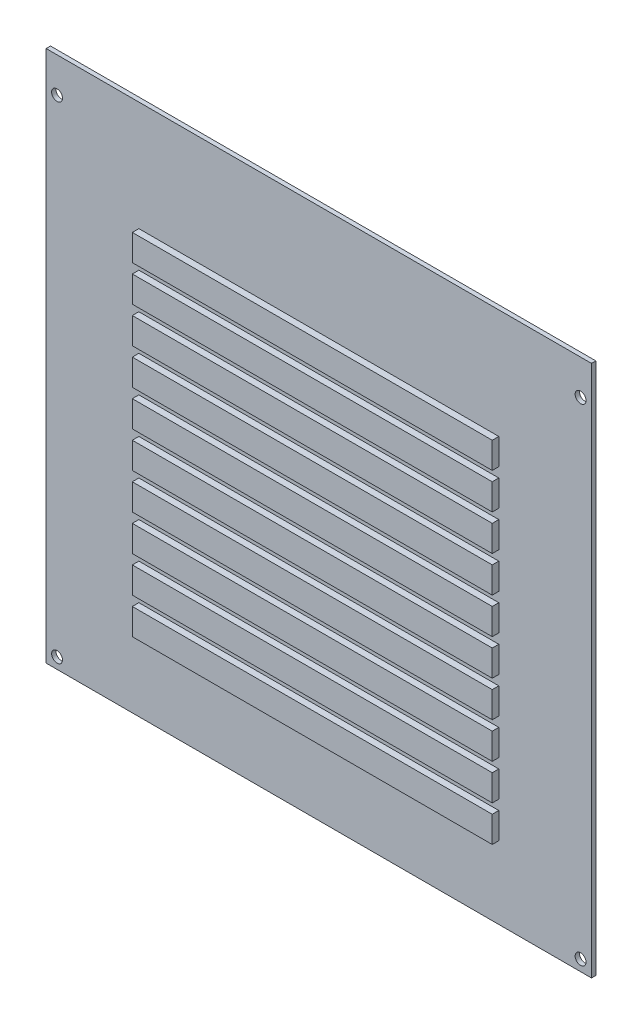
from build123d import *

# Parameters (mm, degrees)
SKIZZE1_W                       = 250
SKIZZE1_H                       = 244
AUFSATZ_LINEAR_AUSTRAGEN1_DEPTH = 2
SKIZZE2_R                       = 2.5
SCHNITT_LINEAR_AUSTRAGEN1_DEPTH = 2
SKIZZE3_W                       = 165
SKIZZE3_H                       = 12
AUFSATZ_LINEAR_AUSTRAGEN2_DEPTH = 3


with BuildPart() as part:
    # Skizze1 → Aufsatz-Linear austragen1 (new body)
    with BuildSketch(Plane.XY):
        with Locations((-125, 122)):
            Rectangle(SKIZZE1_W, SKIZZE1_H)
    extrude(amount=AUFSATZ_LINEAR_AUSTRAGEN1_DEPTH)

    # Skizze2 → Schnitt-Linear austragen1 (cut)
    with BuildSketch(Plane.XY.offset(2)):
        with Locations((-245, 5)):
            Circle(SKIZZE2_R)
        with Locations((-5, 5)):
            Circle(SKIZZE2_R)
        with Locations((-245, 228)):
            Circle(SKIZZE2_R)
        with Locations((-5, 228)):
            Circle(SKIZZE2_R)
    extrude(amount=-SCHNITT_LINEAR_AUSTRAGEN1_DEPTH, mode=Mode.SUBTRACT)

    # Skizze3 → Aufsatz-Linear austragen2 (add)
    with BuildSketch(Plane.XY.offset(2)):
        with Locations((-125, 39.25)):
            Rectangle(SKIZZE3_W, SKIZZE3_H)
        with Locations((-125, 55.75)):
            Rectangle(SKIZZE3_W, SKIZZE3_H)
        with Locations((-125, 72.25)):
            Rectangle(SKIZZE3_W, SKIZZE3_H)
        with Locations((-125, 88.75)):
            Rectangle(SKIZZE3_W, SKIZZE3_H)
        with Locations((-125, 105.25)):
            Rectangle(SKIZZE3_W, SKIZZE3_H)
        with Locations((-125, 121.75)):
            Rectangle(SKIZZE3_W, SKIZZE3_H)
        with Locations((-125, 138.25)):
            Rectangle(SKIZZE3_W, SKIZZE3_H)
        with Locations((-125, 154.75)):
            Rectangle(SKIZZE3_W, SKIZZE3_H)
        with Locations((-125, 171.25)):
            Rectangle(SKIZZE3_W, SKIZZE3_H)
        with Locations((-125, 187.75)):
            Rectangle(SKIZZE3_W, SKIZZE3_H)
    extrude(amount=AUFSATZ_LINEAR_AUSTRAGEN2_DEPTH)


solid = part.part
